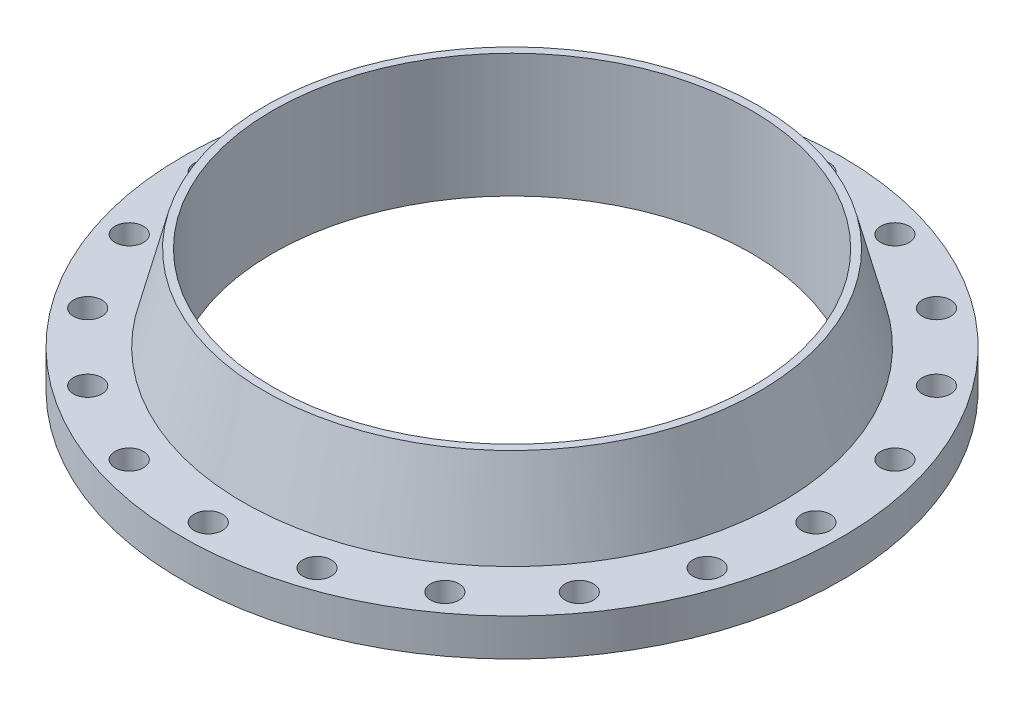
from build123d import *

# Parameters (mm, degrees)
SKETCH10_R         = 0.69
CUT_EXTRUDE1_DEPTH = 6.81
CIRPATTERN1_COUNT  = 20
SCALE1_SCALE       = 25.4


with BuildPart() as part:
    # Sketch8 → Revolve1 (revolve)
    with BuildSketch(Plane.XY):
        Polygon((-11.625, 0), (-11.625, 5.94), (-12, 5.94), (-13.06, 1.81), (-16, 1.81), (-16, 0), (-13.625, 0), (-13.625, -0.0625), (-11.625, -0.0625), align=None)
    revolve(axis=Axis((0, 0, 0), (0, 1, 0)))

    # Sketch10 → Cut-Extrude1 (cut)
    with BuildSketch(Plane(origin=(0, 0, 0), x_dir=(1, 0, 0), z_dir=(0, 1, 0))):
        with Locations((0, 14.75)):
            Circle(SKETCH10_R)
    cut_extrude1 = extrude(amount=CUT_EXTRUDE1_DEPTH, mode=Mode.SUBTRACT)

    # CirPattern1: Cut-Extrude1 ×20 about axis
    cirpattern1_axis = Axis((0, 0, 0), (0, 1, 0))
    for i in range(1, CIRPATTERN1_COUNT):
        add(cut_extrude1.rotate(cirpattern1_axis, i * 360 / CIRPATTERN1_COUNT), mode=Mode.SUBTRACT)


with BuildPart() as part_1:
    # Scale1: scaled about (0, 1.678925008, 0)
    add(part.part.scale(SCALE1_SCALE).moved(Location((0, -40.965770195, 0))))


solid = part_1.part
